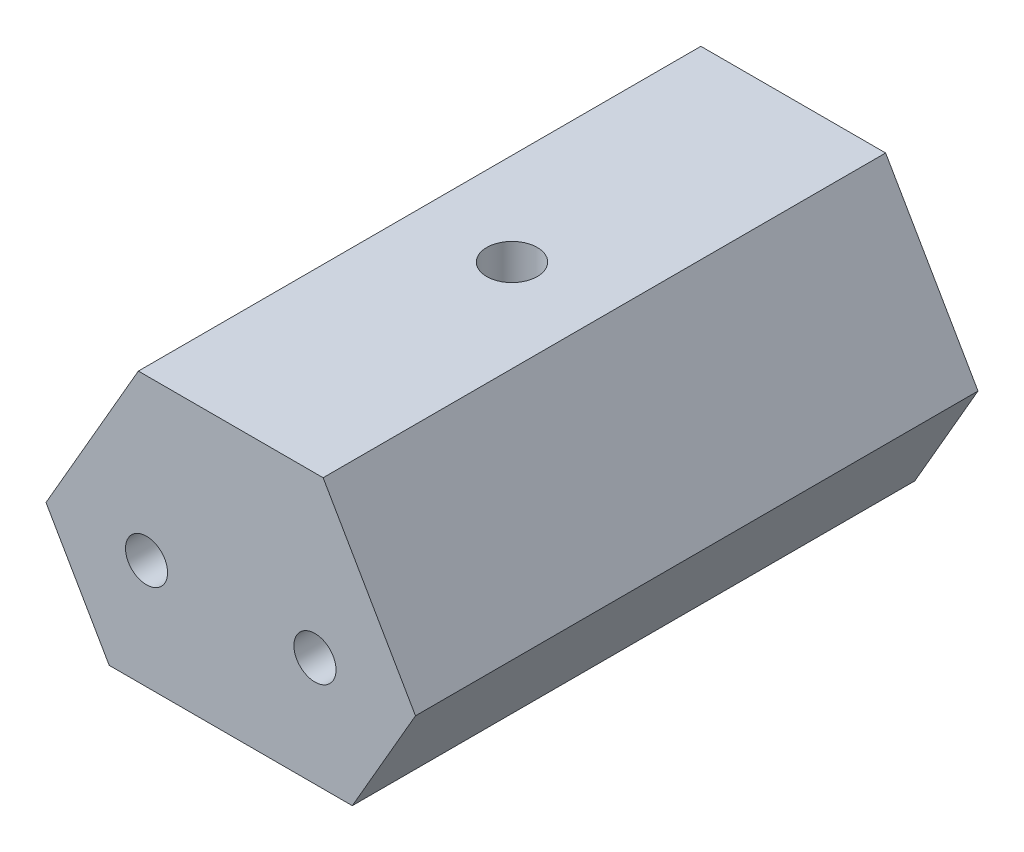
from build123d import *

# Parameters (mm, degrees)
SKETCH1_R                   = 1.25
BOSS_EXTRUDE1_DEPTH         = 16.7
F_1_4_28_TAPPED_HOLE1_D     = 3
F_1_4_28_TAPPED_HOLE1_DEPTH = 16


with BuildPart() as part:
    # Sketch1 → Boss-Extrude1 (new body, symmetric)
    with BuildSketch(Plane.XY):
        Polygon((-7.216878365, -6.5), (7.216878365, -6.5), (10.969655115, 0), (5.484827557, 9.5), (-5.484827557, 9.5), (-10.969655115, 0), align=None)
        with Locations((-5, 0)):
            Circle(SKETCH1_R, mode=Mode.SUBTRACT)
        with Locations((5, 0)):
            Circle(SKETCH1_R, mode=Mode.SUBTRACT)
    extrude(amount=BOSS_EXTRUDE1_DEPTH, both=True)

    # 1/4-28 Tapped Hole1
    with Locations(Plane(origin=(0, 9.5, 0), x_dir=(1, 0, 0), z_dir=(0, 1, 0))):
        with Locations((0, 0)):
            Hole(F_1_4_28_TAPPED_HOLE1_D / 2, depth=F_1_4_28_TAPPED_HOLE1_DEPTH)


solid = part.part
